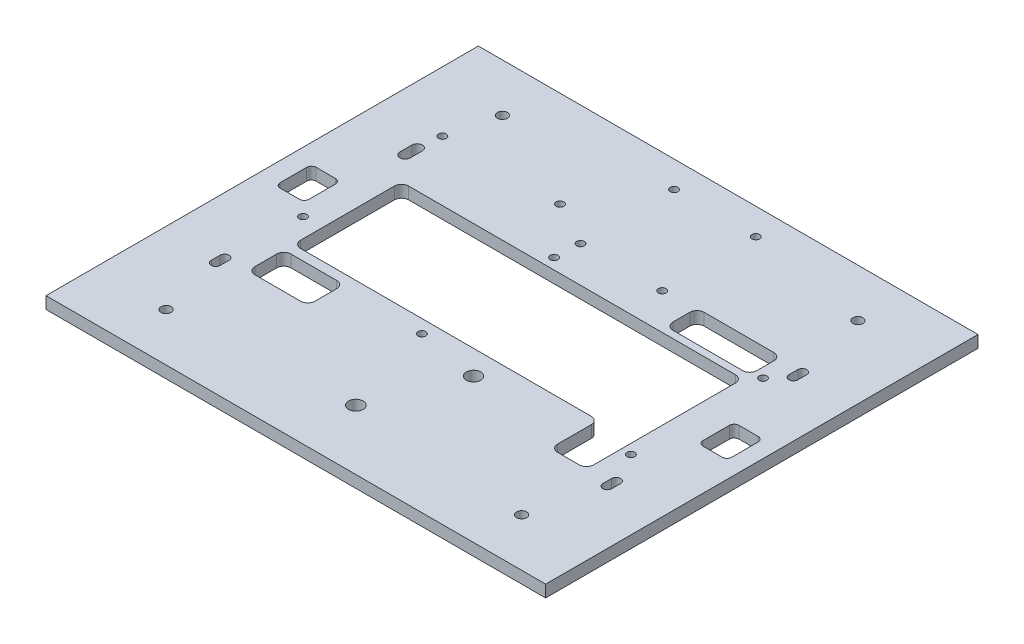
from build123d import *

# Parameters (mm, degrees)
D_KESIM_W                   = 208
D_KESIM_H                   = 180
ANA_PLAKA_DEPTH             = 5
BASEBOARD_PI_R              = 1.6
BASE_PI_DEPTH               = 6
KASA_BA_LANT_LAR_DEPTH      = 6
SKETCH3_R                   = 3
LIPO_YUVAS_DEPTH            = 6
SKETCH1_R                   = 1.6
MAINBOARD_DEPTH             = 6
SKETCH5_R                   = 2.1
VIDA_DELIKLERI_DEPTH        = 6
KABLO_AKTAR_M_BO_LU_U_DEPTH = 6
SHARP_SENSOR_DEPTH          = 6
SKETCH11_R                  = 3.05
STOP_BUTON_DEPTH            = 6
SKETCH10_R                  = 1.6
MOTOR_DRIVER_DEPTH          = 6


with BuildPart() as part:
    # Dış Kesim → Ana Plaka (new body)
    with BuildSketch(Plane(origin=(0, 0, 0), x_dir=(1, 0, 0), z_dir=(0, 1, 0))):
        Rectangle(D_KESIM_W, D_KESIM_H)
    extrude(amount=ANA_PLAKA_DEPTH)

    # BaseBoard + Pi → Base - Pi (cut, through all)
    with BuildSketch(Plane(origin=(0, 0, 0), x_dir=(1, 0, 0), z_dir=(0, 1, 0))):
        with Locations((-30, 50)):
            Circle(BASEBOARD_PI_R)
        with Locations((-79, 50)):
            Circle(BASEBOARD_PI_R)
        with Locations((-79, -8)):
            Circle(BASEBOARD_PI_R)
    extrude(amount=BASE_PI_DEPTH, mode=Mode.SUBTRACT)

    # Sketch2 → Kasa Bağlantıları (cut, through all)
    with BuildSketch(Plane(origin=(0, 5, 0), x_dir=(1, 0, 0), z_dir=(0, 1, 0))):
        with BuildLine():
            Line((-82.15, 35.5), (-82.15, 40.5))
            ThreePointArc((-82.15, 40.5), (-80, 42.65), (-77.85, 40.5))
            Line((-77.85, 40.5), (-77.85, 35.5))
            ThreePointArc((-77.85, 35.5), (-80, 33.35), (-82.15, 35.5))
        make_face()
        with BuildLine():
            Line((-82.35, -42.85), (-82.35, -39.15))
            ThreePointArc((-82.35, -39.15), (-80.5, -37.3), (-78.65, -39.15))
            Line((-78.65, -39.15), (-78.65, -42.85))
            ThreePointArc((-78.65, -42.85), (-80.5, -44.7), (-82.35, -42.85))
        make_face()
        with BuildLine():
            Line((79.65, -41.85), (79.65, -38.15))
            ThreePointArc((79.65, -38.15), (81.5, -36.3), (83.35, -38.15))
            Line((83.35, -38.15), (83.35, -41.85))
            ThreePointArc((83.35, -41.85), (81.5, -43.7), (79.65, -41.85))
        make_face()
        with BuildLine():
            Line((79.15, 36.15), (79.15, 39.85))
            ThreePointArc((79.15, 39.85), (81, 41.7), (82.85, 39.85))
            Line((82.85, 39.85), (82.85, 36.15))
            ThreePointArc((82.85, 36.15), (81, 34.3), (79.15, 36.15))
        make_face()
    extrude(amount=-KASA_BA_LANT_LAR_DEPTH, mode=Mode.SUBTRACT)

    # Sketch3 → LiPo Yuvası (cut, through all)
    with BuildSketch(Plane(origin=(0, 5, 0), x_dir=(1, 0, 0), z_dir=(0, 1, 0))):
        with Locations((14, -30)):
            Circle(SKETCH3_R)
        with BuildLine():
            Line((-59, 25), (-68, 25))
            ThreePointArc((-68, 25), (-70.121320344, 24.121320344), (-71, 22))
            Line((-71, 22), (-71, -17))
            ThreePointArc((-71, -17), (-70.121320344, -19.121320344), (-68, -20))
            Line((-68, -20), (53, -20))
            ThreePointArc((53, -20), (55.121320344, -20.878679656), (56, -23))
            Line((56, -23), (56, -37))
            ThreePointArc((56, -37), (56.878679656, -39.121320344), (59, -40))
            Line((59, -40), (68, -40))
            ThreePointArc((68, -40), (70.121320344, -39.121320344), (71, -37))
            Line((71, -37), (71, -15))
            Line((71, -15), (71, 22))
            ThreePointArc((71, 22), (70.121320344, 24.121320344), (68, 25))
            Line((68, 25), (-59, 25))
        make_face()
        with BuildLine():
            Line((-68, -24), (-49, -24))
            ThreePointArc((-49, -24), (-46.878679656, -24.878679656), (-46, -27))
            Line((-46, -27), (-46, -36))
            ThreePointArc((-46, -36), (-46.878679656, -38.121320344), (-49, -39))
            Line((-49, -39), (-68, -39))
            ThreePointArc((-68, -39), (-70.121320344, -38.121320344), (-71, -36))
            Line((-71, -36), (-71, -27))
            ThreePointArc((-71, -27), (-70.121320344, -24.878679656), (-68, -24))
        make_face()
    extrude(amount=-LIPO_YUVAS_DEPTH, mode=Mode.SUBTRACT)

    # Sketch1 → MainBoard (cut, through all)
    with BuildSketch(Plane(origin=(0, 5, 0), x_dir=(1, 0, 0), z_dir=(0, 1, 0))):
        with Locations((-12, 29.5)):
            Circle(SKETCH1_R)
        with Locations((75, 29.5)):
            Circle(SKETCH1_R)
        with Locations((75, -25.5)):
            Circle(SKETCH1_R)
        with Locations((-12, -25.5)):
            Circle(SKETCH1_R)
    extrude(amount=-MAINBOARD_DEPTH, mode=Mode.SUBTRACT)

    # Sketch5 → Vida Delikleri (cut, through all)
    with BuildSketch(Plane(origin=(0, 5, 0), x_dir=(1, 0, 0), z_dir=(0, 1, 0))):
        with Locations((-74, 70)):
            Circle(SKETCH5_R)
        with Locations((74, 70)):
            Circle(SKETCH5_R)
        with Locations((74, -70)):
            Circle(SKETCH5_R)
        with Locations((-74, -70)):
            Circle(SKETCH5_R)
    extrude(amount=-VIDA_DELIKLERI_DEPTH, mode=Mode.SUBTRACT)

    # Sketch8 → Kablo Aktarım Boşluğu (cut, through all)
    with BuildSketch(Plane(origin=(0, 5, 0), x_dir=(1, 0, 0), z_dir=(0, 1, 0))):
        with BuildLine():
            Line((68, 41), (39, 41))
            ThreePointArc((39, 41), (36.878679656, 40.121320344), (36, 38))
            Line((36, 38), (36, 31))
            ThreePointArc((36, 31), (36.878679656, 28.878679656), (39, 28))
            Line((39, 28), (68, 28))
            ThreePointArc((68, 28), (70.121320344, 28.878679656), (71, 31))
            Line((71, 31), (71, 38))
            ThreePointArc((71, 38), (70.121320344, 40.121320344), (68, 41))
        make_face()
    extrude(amount=-KABLO_AKTAR_M_BO_LU_U_DEPTH, mode=Mode.SUBTRACT)

    # Sketch9 → Sharp Sensor (cut, through all)
    with BuildSketch(Plane(origin=(0, 5, 0), x_dir=(1, 0, 0), z_dir=(0, 1, 0))):
        with BuildLine():
            Line((-94, 12.5), (-86, 12.5))
            ThreePointArc((-86, 12.5), (-84.585786438, 11.914213562), (-84, 10.5))
            Line((-84, 10.5), (-84, -0.5))
            ThreePointArc((-84, -0.5), (-84.585786438, -1.914213562), (-86, -2.5))
            Line((-86, -2.5), (-94, -2.5))
            ThreePointArc((-94, -2.5), (-95.414213562, -1.914213562), (-96, -0.5))
            Line((-96, -0.5), (-96, 10.5))
            ThreePointArc((-96, 10.5), (-95.414213562, 11.914213562), (-94, 12.5))
        make_face()
        with BuildLine():
            Line((95, 7.5), (87, 7.5))
            ThreePointArc((87, 7.5), (85.585786438, 6.914213562), (85, 5.5))
            Line((85, 5.5), (85, -5.5))
            ThreePointArc((85, -5.5), (85.585786438, -6.914213562), (87, -7.5))
            Line((87, -7.5), (95, -7.5))
            ThreePointArc((95, -7.5), (96.414213562, -6.914213562), (97, -5.5))
            Line((97, -5.5), (97, 5.5))
            ThreePointArc((97, 5.5), (96.414213562, 6.914213562), (95, 7.5))
        make_face()
    extrude(amount=-SHARP_SENSOR_DEPTH, mode=Mode.SUBTRACT)

    # Sketch11 → Stop Buton (cut, through all)
    with BuildSketch(Plane(origin=(0, 5, 0), x_dir=(1, 0, 0), z_dir=(0, 1, 0))):
        with Locations((0, -65)):
            Circle(SKETCH11_R)
    extrude(amount=-STOP_BUTON_DEPTH, mode=Mode.SUBTRACT)

    # Sketch10 → Motor Driver (cut, through all)
    with BuildSketch(Plane(origin=(0, 5, 0), x_dir=(1, 0, 0), z_dir=(0, 1, 0))):
        with Locations((-11.5, 40)):
            Circle(SKETCH10_R)
        with Locations((22.5, 40)):
            Circle(SKETCH10_R)
        with Locations((-11.5, 79)):
            Circle(SKETCH10_R)
        with Locations((22.5, 79)):
            Circle(SKETCH10_R)
    extrude(amount=-MOTOR_DRIVER_DEPTH, mode=Mode.SUBTRACT)


solid = part.part
